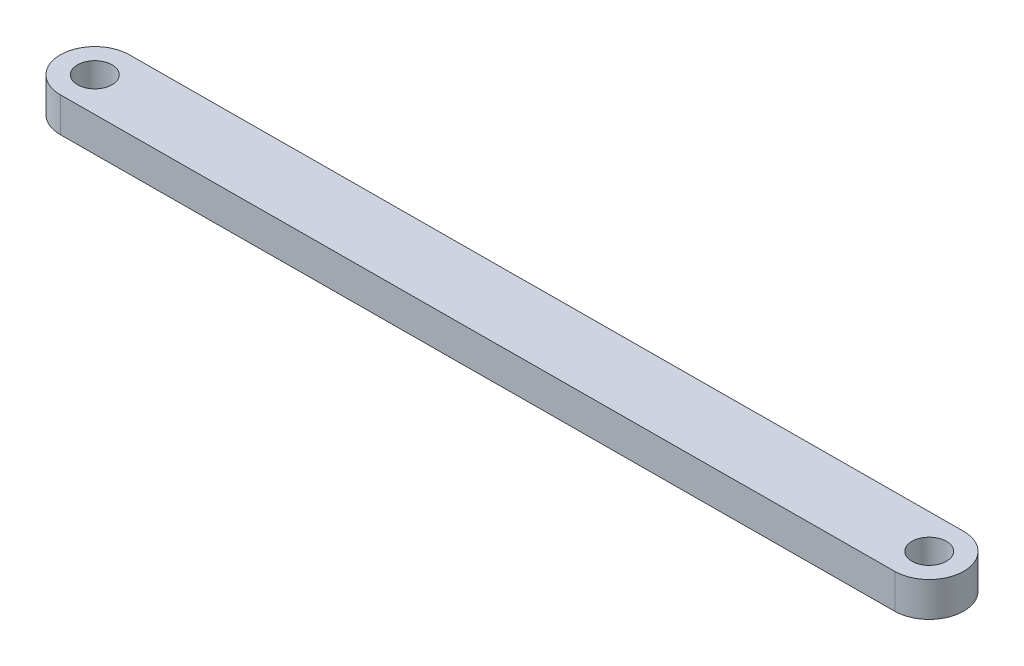
from build123d import *

# Parameters (mm, degrees)
SKETCH1_R           = 6.35
BOSS_EXTRUDE1_DEPTH = 12.7


with BuildPart() as part:
    # Sketch1 → Boss-Extrude1 (new body)
    with BuildSketch(Plane(origin=(0, 0, 0), x_dir=(1, 0, 0), z_dir=(0, 1, 0))):
        with BuildLine():
            Line((-0.068893261, 12.699813137), (304.731106739, 14.353275727))
            ThreePointArc((304.731106739, 14.353275727), (317.499813137, 1.722355851), (304.868893261, -11.046350547))
            Line((304.868893261, -11.046350547), (0.068893261, -12.699813137))
            ThreePointArc((0.068893261, -12.699813137), (-12.699813137, -0.068893261), (-0.068893261, 12.699813137))
        make_face()
        Circle(SKETCH1_R, mode=Mode.SUBTRACT)
        with Locations((304.8, 1.65346259)):
            Circle(SKETCH1_R, mode=Mode.SUBTRACT)
    extrude(amount=BOSS_EXTRUDE1_DEPTH)


solid = part.part
